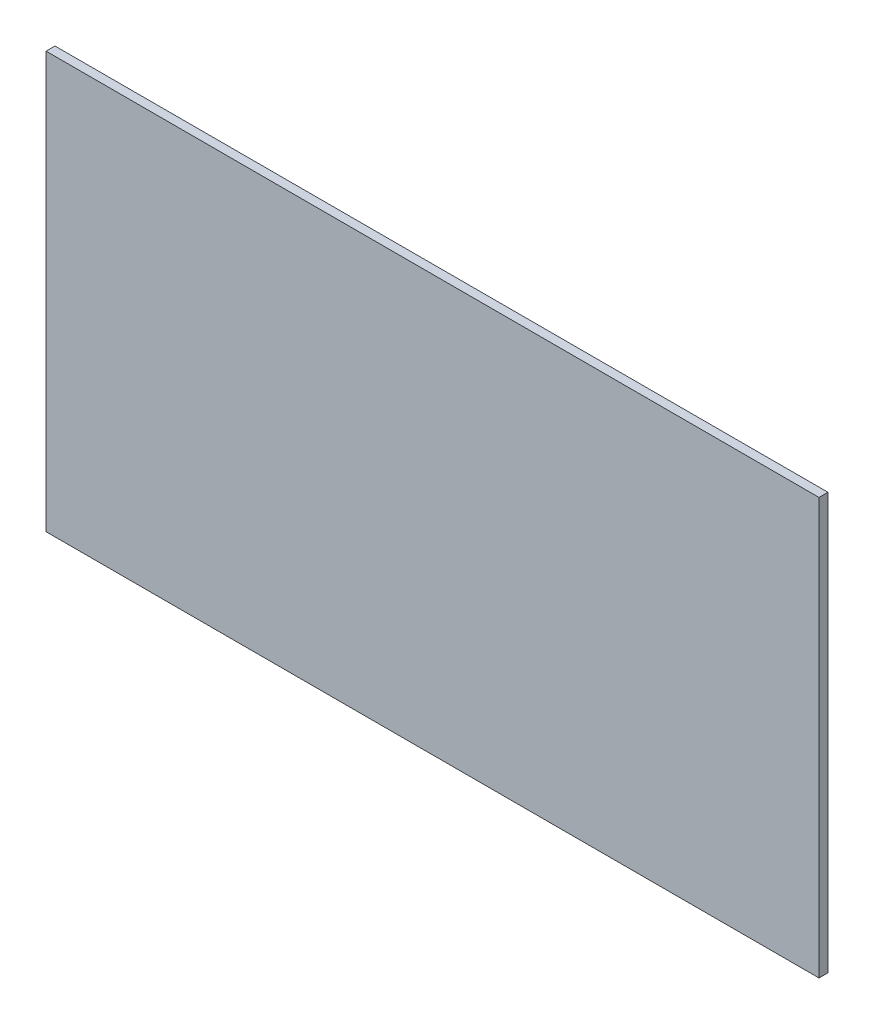
from build123d import *

# Parameters (mm, degrees)
SKETCH1_W           = 130
SKETCH1_H           = 70
BOSS_EXTRUDE1_DEPTH = 1.5


with BuildPart() as part:
    # Sketch1 → Boss-Extrude1 (new body)
    with BuildSketch(Plane.XY):
        Rectangle(SKETCH1_W, SKETCH1_H)
    extrude(amount=BOSS_EXTRUDE1_DEPTH)


solid = part.part
